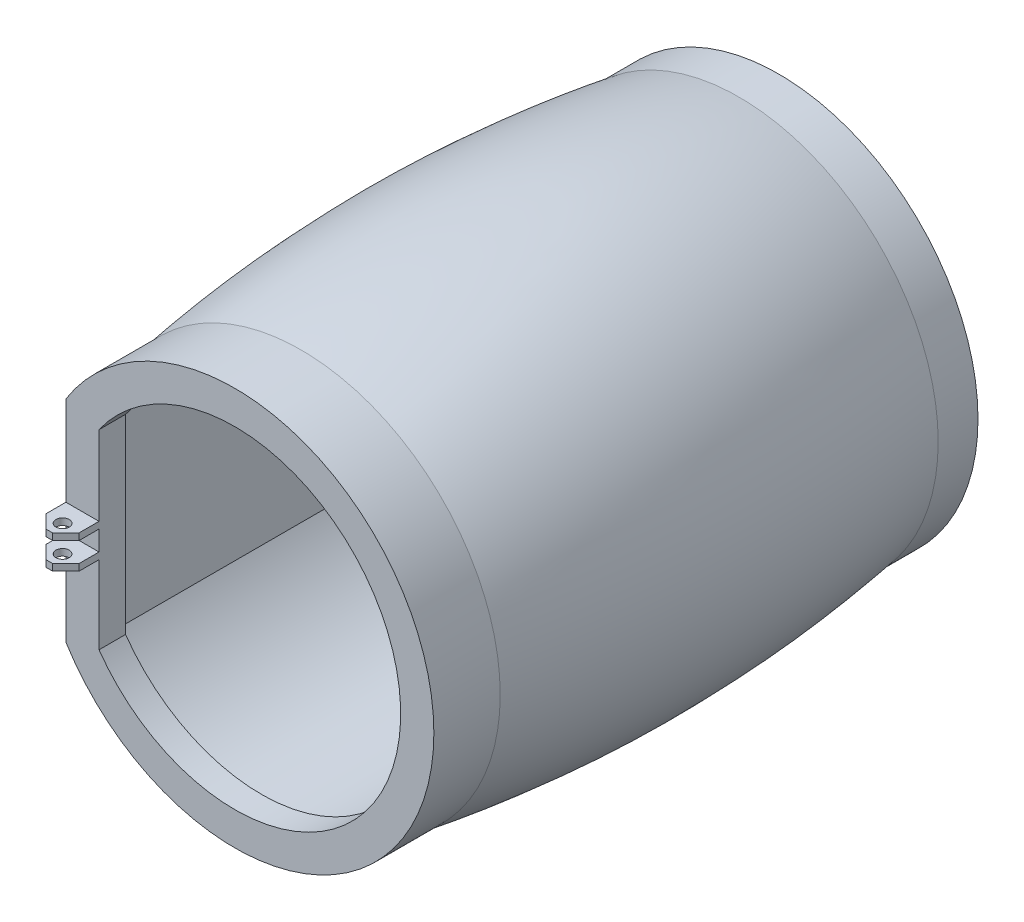
from build123d import *

# Parameters (mm, degrees)
BOSS_EXTRUDE1_DEPTH       = 33
CUT_EXTRUDE2_DEPTH        = 33
CUT_EXTRUDE3_DEPTH        = 33
SKETCH5_R                 = 15
SKETCH5_R_2               = 13.5
BOSS_EXTRUDE2_DEPTH       = 3
SKETCH6_R                 = 15
SKETCH6_R_2               = 13.5
BOSS_EXTRUDE6_DEPTH       = 3
BOSS_EXTRUDE8_DEPTH       = 1
BOSS_EXTRUDE9_DEPTH       = 1
CUT_EXTRUDE4_DEPTH        = 43
BOSS_EXTRUDE16_DEPTH      = 3
BOSS_EXTRUDE16_DEPTH_BACK = 36
BOSS_EXTRUDE18_DEPTH      = 2
CUT_EXTRUDE5_DEPTH        = 6
SKETCH15_W                = 2.495675776
SKETCH15_H                = 2.5
BOSS_EXTRUDE19_DEPTH      = 2.5
SKETCH16_W                = 2.495675776
SKETCH16_H                = 1.5
CUT_EXTRUDE6_DEPTH        = 2.5
SKETCH17_R                = 0.5
CUT_EXTRUDE7_DEPTH        = 2.5
CHAMFER1_SIZE             = 1


with BuildPart() as part:
    # Sketch1 → Boss-Extrude1 (new body)
    with BuildSketch(Plane.XY):
        with BuildLine():
            Line((-12.730582936, -7.932985447), (-12.730582936, 7.932985447))
            ThreePointArc((-12.730582936, 7.932985447), (15, 0), (-12.730582936, -7.932985447))
        make_face()
    extrude(amount=BOSS_EXTRUDE1_DEPTH)

    # Sketch2 → Cut-Extrude2 (cut)
    with BuildSketch(Plane.XY.offset(33)):
        with BuildLine():
            Line((-11.23, 7.492469553), (-11.23, -7.492469553))
            ThreePointArc((-11.23, -7.492469553), (13.5, 0), (-11.23, 7.492469553))
        make_face()
    extrude(amount=-CUT_EXTRUDE2_DEPTH, mode=Mode.SUBTRACT)

    # Sketch3 → Revolve1 (revolve)
    with BuildSketch(Plane(origin=(0, 0, 0), x_dir=(1, 0, 0), z_dir=(0, 1, 0))):
        with BuildLine():
            Line((15, 0), (15, -33))
            add(Edge.make_bspline(
                [(15, 0), (17.606147379, -16.5), (15, -33)],
                knots=[0, 0, 0, 1, 1, 1], degree=2))
        make_face()
    revolve(axis=Axis((0, 0, 1000), (0, 0, -1)))

    # Sketch4 → Cut-Extrude3 (cut)
    with BuildSketch(Plane(origin=(0, 0, 0), x_dir=(-1, 0, 0), z_dir=(0, 0, -1))):
        Polygon((12.730582936, 16.416653829), (12.730582936, -13.128756539), (18.380259155, -13.128756539), (18.380259155, 16.827640991), align=None)
    extrude(amount=-CUT_EXTRUDE3_DEPTH, mode=Mode.SUBTRACT)

    # Sketch5 → Boss-Extrude2 (add)
    with BuildSketch(Plane.XY.offset(33)):
        with Locations(Location((0, 0, 0), (0, 0, 211.9288465))):
            Circle(SKETCH5_R)
        Circle(SKETCH5_R_2, mode=Mode.SUBTRACT)
    extrude(amount=BOSS_EXTRUDE2_DEPTH)

    # Sketch6 → Boss-Extrude6 (add)
    with BuildSketch(Plane(origin=(0, 0, 0), x_dir=(-1, 0, 0), z_dir=(0, 0, -1))):
        with Locations(Location((0, 0, 0), (0, 0, 328.0711535))):
            Circle(SKETCH6_R)
        with Locations(Location((0, 0, 0), (0, 0, 180))):
            Circle(SKETCH6_R_2, mode=Mode.SUBTRACT)
    extrude(amount=BOSS_EXTRUDE6_DEPTH)

    # Sketch7 → Boss-Extrude8 (add)
    with BuildSketch(Plane(origin=(0, 0, 0), x_dir=(-1, 0, 0), z_dir=(0, 0, -1))):
        with BuildLine():
            Line((12.730582936, 4.492466817), (12.730582936, -4.320544614))
            add(Edge.make_bspline(
                [(12.730582936, 4.492466817), (14.26616245, 0.098577046), (12.730582936, -4.320544614)],
                knots=[0, 0, 0, 1, 1, 1], degree=2))
        make_face()
    extrude(amount=-BOSS_EXTRUDE8_DEPTH)

    # Sketch8 → Boss-Extrude9 (add)
    with BuildSketch(Plane.XY.offset(33)):
        with BuildLine():
            Line((-12.730582936, 4.492466817), (-12.730582936, -4.320544614))
            add(Edge.make_bspline(
                [(-12.730582936, 4.492466817), (-13.227968128, 3.051756818), (-13.780379485, 0.057351366), (-13.212282114, -2.937471643), (-12.730582936, -4.320544614)],
                knots=[0, 0, 0, 0, 0.509558316, 1, 1, 1, 1], degree=3))
        make_face()
    extrude(amount=-BOSS_EXTRUDE9_DEPTH)

    # Sketch10 → Cut-Extrude4 (cut)
    with BuildSketch(Plane(origin=(0, 0, -3), x_dir=(-1, 0, 0), z_dir=(0, 0, -1))):
        Polygon((12.730582936, 10.184422901), (12.730582936, -10.184422901), (17.774387551, -7.968584404), (17.180739429, 9.475537328), align=None)
    extrude(amount=-CUT_EXTRUDE4_DEPTH, mode=Mode.SUBTRACT)

    # Sketch12 → Boss-Extrude16 (add, two sides)
    with BuildSketch(Plane.XY.offset(33)) as boss_extrude16_sk:
        Polygon((-11.23, 7.492469553), (-11.23, -7.492469553), (-12.730582936, -7.492469553), (-12.730582936, -4.492466817), (-12.730582936, 4.492466817), (-12.730582936, 7.492469553), align=None)
    extrude(amount=BOSS_EXTRUDE16_DEPTH)
    extrude(boss_extrude16_sk.sketch, amount=-BOSS_EXTRUDE16_DEPTH_BACK)

    # Sketch13 → Boss-Extrude18 (add)
    with BuildSketch(Plane.XY.offset(36)):
        with BuildLine():
            Line((-12.730582936, 7.932985447), (-12.730582936, -7.932985447))
            ThreePointArc((-12.730582936, -7.932985447), (15, 0), (-12.730582936, 7.932985447))
        make_face()
        with BuildLine():
            Line((-11.23, -7.492469553), (-11.23, 7.492469553))
            ThreePointArc((-11.23, 7.492469553), (13.5, 0), (-11.23, -7.492469553))
        make_face(mode=Mode.SUBTRACT)
        with BuildLine():
            ThreePointArc((-11.23, 7.492469553), (13.5, 0), (-11.23, -7.492469553))
            Line((-11.23, -7.492469553), (-11.23, 7.492469553))
        make_face()
    extrude(amount=BOSS_EXTRUDE18_DEPTH)

    # Sketch14 → Cut-Extrude5 (cut)
    with BuildSketch(Plane.XY.offset(38)):
        with BuildLine():
            Line((-10.23, 7.183112139), (-10.23, -7.183112139))
            ThreePointArc((-10.23, -7.183112139), (12.5, 0), (-10.23, 7.183112139))
        make_face()
    extrude(amount=-CUT_EXTRUDE5_DEPTH, mode=Mode.SUBTRACT)

    # Sketch15 → Boss-Extrude19 (add)
    with BuildSketch(Plane.XY.offset(38)):
        with Locations((-11.477837888, -0.051459344)):
            Rectangle(SKETCH15_W, SKETCH15_H)
    extrude(amount=BOSS_EXTRUDE19_DEPTH)

    # Sketch16 → Cut-Extrude6 (cut)
    with BuildSketch(Plane.XY.offset(40.5)):
        with Locations((-11.477837888, -0.051459344)):
            Rectangle(SKETCH16_W, SKETCH16_H)
    extrude(amount=-CUT_EXTRUDE6_DEPTH, mode=Mode.SUBTRACT)

    # Sketch17 → Cut-Extrude7 (cut)
    with BuildSketch(Plane.XZ.offset(1.301459344)):
        with Locations(Location((-11.477837888, 39.5, 0), (0, 0, 270))):
            Circle(SKETCH17_R)
    extrude(amount=-CUT_EXTRUDE7_DEPTH, mode=Mode.SUBTRACT)

    # Chamfer1
    chamfer1_edges = [part.edges().sort_by_distance(p)[0] for p in [
        (-12.725675776, -1.051459344, 40.5),
        (-12.725675776, 0.948540656, 40.5),
        (-10.23, -1.051459344, 40.5),
        (-10.23, 0.948540656, 40.5),
    ]]
    chamfer(chamfer1_edges, length=CHAMFER1_SIZE)


solid = part.part
